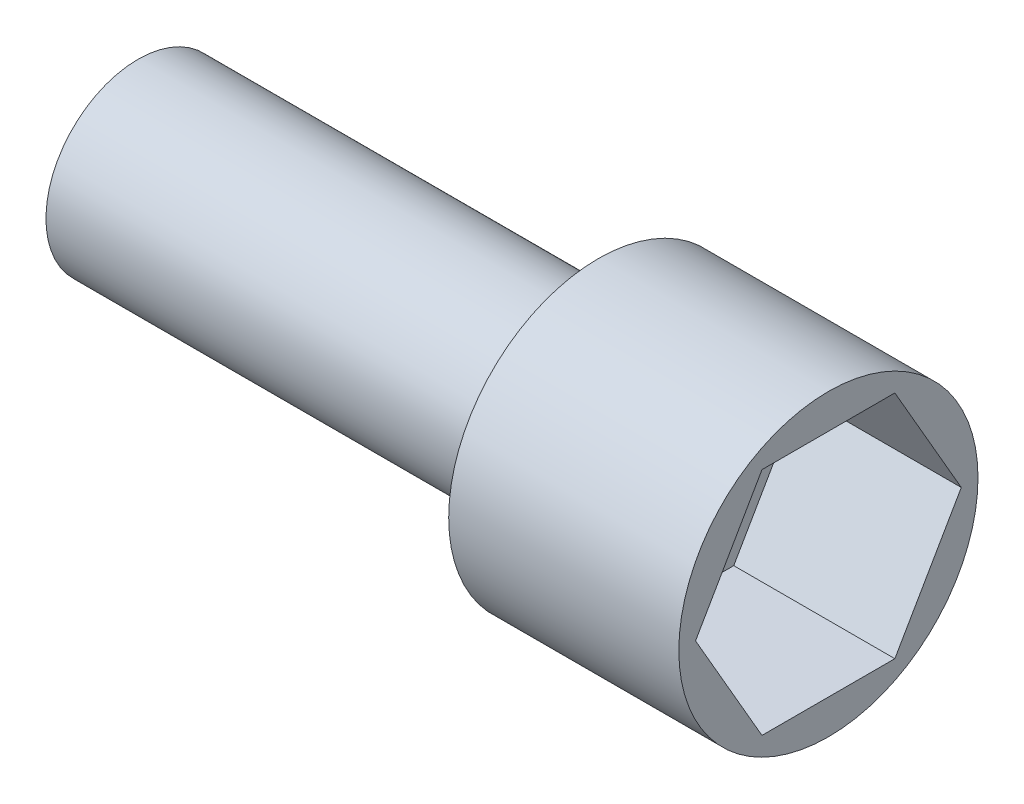
from build123d import *

# Parameters (mm, degrees)
CUT_EXTRUDE1_DEPTH = 7


with BuildPart() as part:
    # Sketch1 → Revolve1 (revolve)
    with BuildSketch(Plane.XY):
        Polygon((15, 0), (-15, 0), (-15, 4), (5, 4), (5, 6.5), (15, 6.5), align=None)
    revolve(axis=Axis((15, 0, 0), (-1, 0, 0)))

    # Sketch2 → Cut-Extrude1 (cut)
    with BuildSketch(Plane(origin=(15, 0, 0), x_dir=(0, 0, -1), z_dir=(1, 0, 0))):
        Polygon((5.773502692, 0), (2.886751346, 5), (-2.886751346, 5), (-5.773502692, 0), (-2.886751346, -5), (2.886751346, -5), align=None)
    extrude(amount=-CUT_EXTRUDE1_DEPTH, mode=Mode.SUBTRACT)


solid = part.part
